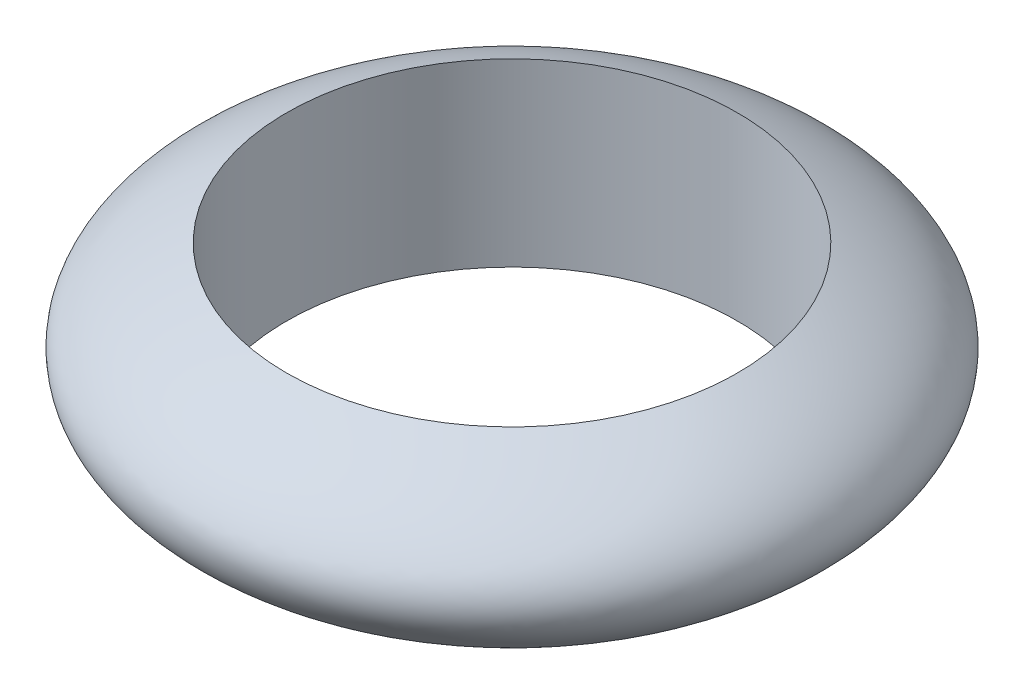
from build123d import *


with BuildPart() as part:
    # 草图1 → 旋转1 (revolve)
    with BuildSketch(Plane.XY):
        with BuildLine():
            Line((-12.5, 0.441176471), (-12.5, 10.441176471))
            add(Edge.make_bspline(
                [(-12.5, 10.441176471), (-24.044117647, 5.441176471), (-12.5, 0.441176471)],
                knots=[0, 0, 0, 1, 1, 1], degree=2))
        make_face()
    revolve(axis=Axis((0, 36.102941176, 0), (0, -1, 0)))


solid = part.part
